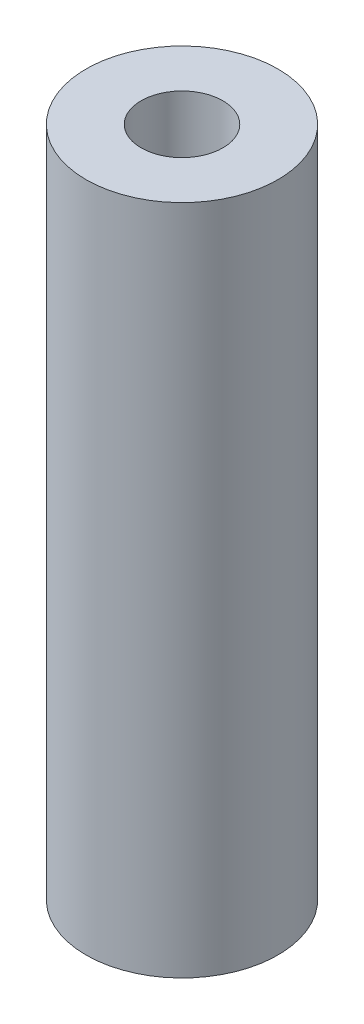
from build123d import *

# Parameters (mm, degrees)
SKETCH1_R                 = 3.175
BOSS_EXTRUDE1_DEPTH       = 22.225
TAP_DRILL_FOR_6_32_TAP1_D = 2.7051


with BuildPart() as part:
    # Sketch1 → Boss-Extrude1 (new body)
    with BuildSketch(Plane(origin=(0, 0, 0), x_dir=(1, 0, 0), z_dir=(0, 1, 0))):
        Circle(SKETCH1_R)
    extrude(amount=BOSS_EXTRUDE1_DEPTH)

    # Tap Drill for #6-32 Tap1 (through all)
    with Locations(Plane(origin=(0, 22.225, 0), x_dir=(1, 0, 0), z_dir=(0, 1, 0))):
        with Locations((0, 0)):
            Hole(TAP_DRILL_FOR_6_32_TAP1_D / 2)


solid = part.part
